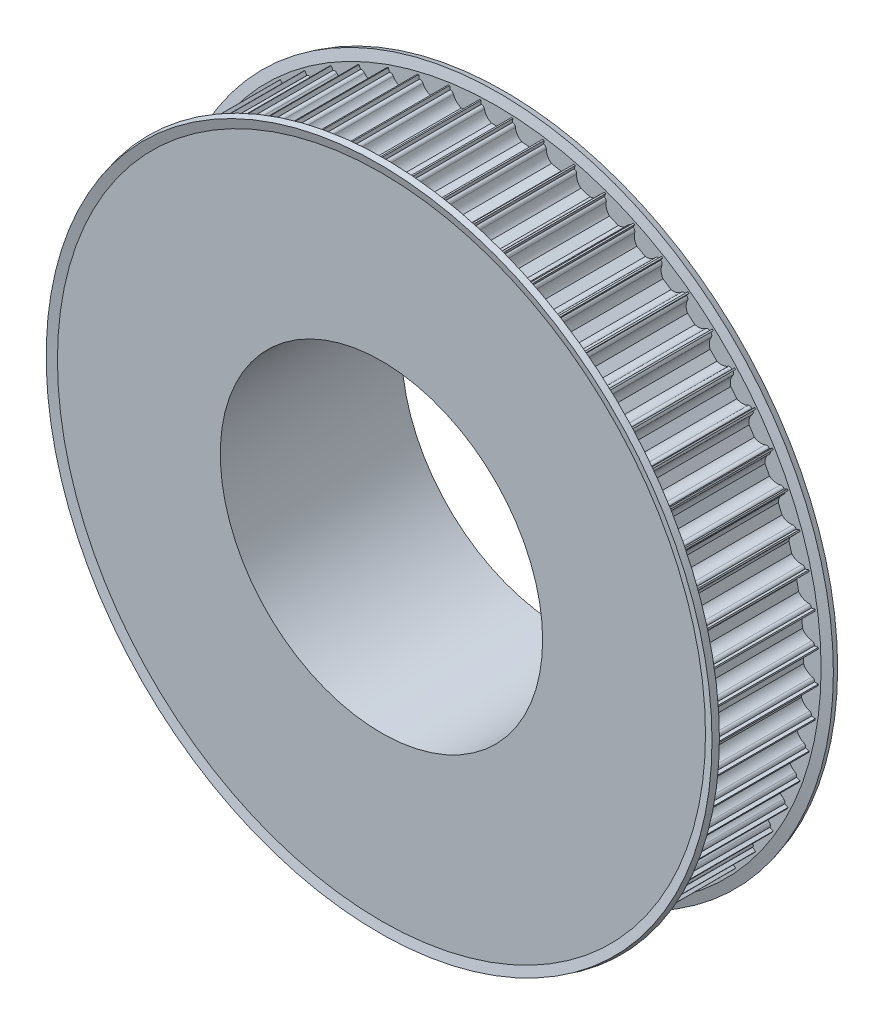
from build123d import *

# Parameters (mm, degrees)
ENL_V_MAT_EXTRU_1_DEPTH      = 46
R_P_TITION_CIRCULAIRE1_COUNT = 64


with BuildPart() as part:
    # Esquisse1 → Révolution1 (revolve)
    with BuildSketch(Plane(origin=(0, 0, 0), x_dir=(0, 0, -1), z_dir=(1, 0, 0))):
        Polygon((0, 40), (0, 80), (30, 80), (30, 55.5), (45, 55.5), (45, 40), align=None)
    revolve(axis=Axis((0, 0, 55), (0, 0, -1)))

    # Esquisse2 → Enlèv. mat.-Extru.1 (cut, through all)
    with BuildSketch(Plane.XY):
        with BuildLine():
            Line((3.674234614, 79), (3.75, 79))
            Line((3.75, 79), (3.75, 81))
            Line((3.75, 81), (-3.75, 81))
            Line((-3.75, 81), (-3.75, 79))
            Line((-3.75, 79), (-3.674234614, 79))
            ThreePointArc((-3.674234614, 79), (-3.199892965, 78.830947502), (-2.939387691, 78.4))
            ThreePointArc((-2.939387691, 78.4), (-2.331759211, 77.112435701), (-1.198957881, 76.25))
            Line((-1.198957881, 76.25), (1.198957881, 76.25))
            ThreePointArc((1.198957881, 76.25), (2.331759211, 77.112435701), (2.939387691, 78.4))
            ThreePointArc((2.939387691, 78.4), (3.199892965, 78.830947502), (3.674234614, 79))
        make_face()
    enl_v_mat_extru_1 = extrude(amount=-ENL_V_MAT_EXTRU_1_DEPTH, mode=Mode.SUBTRACT)

    # Répétition circulaire1: Enlèv. mat.-Extru.1 ×64 about axis
    r_p_tition_circulaire1_axis = Axis((0, 0, 0), (0, 0, 1))
    for i in range(1, R_P_TITION_CIRCULAIRE1_COUNT):
        add(enl_v_mat_extru_1.rotate(r_p_tition_circulaire1_axis, i * 360 / R_P_TITION_CIRCULAIRE1_COUNT), mode=Mode.SUBTRACT)

    # Esquisse3 → Révolution3 (revolve)
    with BuildSketch(Plane(origin=(0, 0, 0), x_dir=(0, 0, -1), z_dir=(1, 0, 0))):
        Polygon((0, 80.414582296), (0, 75.612061042), (1.5, 75.612061042), (1.5, 80.612061042), (0.856921938, 83.012061042), (-0.591966801, 82.623832474), align=None)
        Polygon((30.591966801, 82.623832474), (29.143078062, 83.012061042), (28.5, 80.612061042), (28.5, 75.612061042), (30, 75.612061042), (30, 80.414582296), align=None)
    revolve(axis=Axis((0, 0, 55), (0, 0, -1)))


solid = part.part
